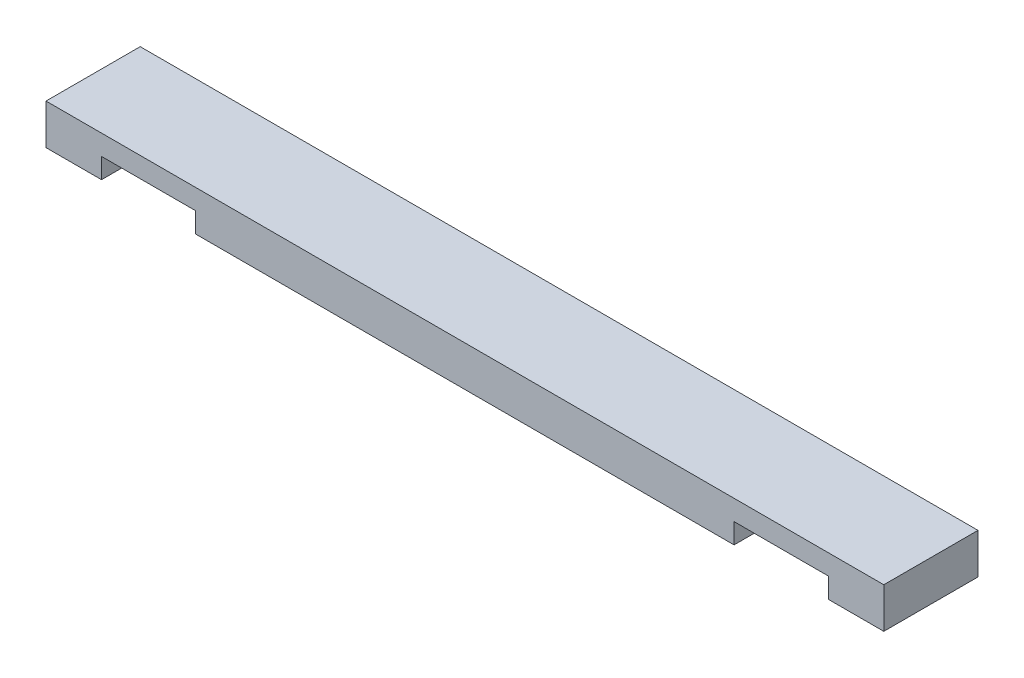
from build123d import *

# Parameters (mm, degrees)
SKETCH1_W           = 790.575
SKETCH1_H           = 88.9
BOSS_EXTRUDE1_DEPTH = 38.1
SKETCH2_W           = 88.9
SKETCH2_H           = 19.05
CUT_EXTRUDE1_DEPTH  = 89.9


with BuildPart() as part:
    # Sketch1 → Boss-Extrude1 (new body)
    with BuildSketch(Plane(origin=(0, 0, 0), x_dir=(1, 0, 0), z_dir=(0, 1, 0))):
        with Locations((395.2875, 44.45)):
            Rectangle(SKETCH1_W, SKETCH1_H)
    extrude(amount=BOSS_EXTRUDE1_DEPTH)

    # Sketch2 → Cut-Extrude1 (cut, through all)
    with BuildSketch(Plane.XY):
        with Locations((693.7375, 9.525)):
            Rectangle(SKETCH2_W, SKETCH2_H)
        with Locations((96.8502, 9.525)):
            Rectangle(SKETCH2_W, SKETCH2_H)
    extrude(amount=-CUT_EXTRUDE1_DEPTH, mode=Mode.SUBTRACT)


solid = part.part
